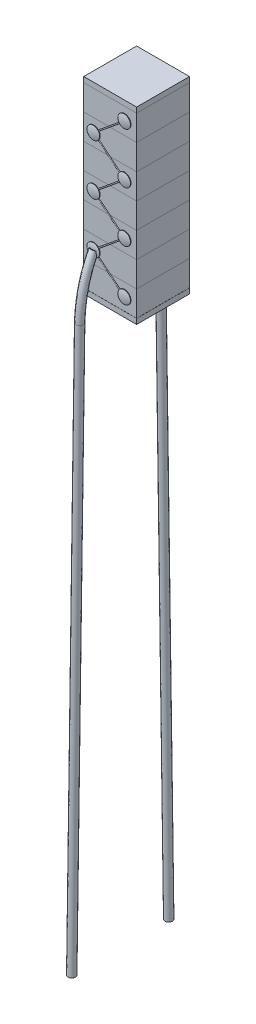
from build123d import *

# Parameters (mm, degrees)
SKETCH1_W                = 5
SKETCH1_H                = 5
BOSS_EXTRUDE1_DEPTH      = 2.4
LPATTERN3_COUNT          = 7
LPATTERN3_PITCH          = 2.4001
SKETCH2_W                = 5
SKETCH2_H                = 5
BOSS_EXTRUDE2_DEPTH      = 0.5
SKETCH7_R                = 0.6
BOSS_EXTRUDE6_DEPTH      = 0.05
DOME1_FACE_RADIUS        = 0.6
DOME1_HEIGHT             = 0.1
DOME5_FACE_RADIUS        = 0.6
DOME5_HEIGHT             = 0.1
DOME6_FACE_RADIUS        = 0.6
DOME6_HEIGHT             = 0.1
DOME7_FACE_RADIUS        = 0.6
DOME7_HEIGHT             = 0.1
SKETCH9_R                = 0.05
SKETCH18_R               = 0.35
DOME10_FACE_RADIUS       = 0.6
DOME10_HEIGHT            = 0.1
DOME11_FACE_RADIUS       = 0.6
DOME11_HEIGHT            = 0.1
DOME12_FACE_RADIUS       = 0.6
DOME12_HEIGHT            = 0.1
MIRROR20_COPY_1_SKETCH_R = 0.05
SKETCH20_W               = 5
SKETCH20_H               = 5
BOSS_EXTRUDE7_DEPTH      = 0.5


with BuildPart() as part:
    # Sketch1 → Boss-Extrude1 (new body)
    with BuildSketch(Plane(origin=(0, 0, 0), x_dir=(1, 0, 0), z_dir=(0, 1, 0))):
        Rectangle(SKETCH1_W, SKETCH1_H)
    extrude(amount=BOSS_EXTRUDE1_DEPTH)


with BuildPart() as lpattern3_1:
    # LPattern3: pattern copy
    add(part.part.moved(Location(Vector(0, 1, 0) * (1 * LPATTERN3_PITCH))))


with BuildPart() as lpattern3_2:
    # LPattern3: pattern copy
    add(part.part.moved(Location(Vector(0, 1, 0) * (2 * LPATTERN3_PITCH))))


with BuildPart() as lpattern3_3:
    # LPattern3: pattern copy
    add(part.part.moved(Location(Vector(0, 1, 0) * (3 * LPATTERN3_PITCH))))

    # Sketch7 → Boss-Extrude6 (add)
    with BuildSketch(Plane.XY.offset(2.5)):
        with Locations((1.368076751, 10.8004)):
            Circle(SKETCH7_R)
        with Locations(Location((-1.547788486, 8.4, 0), (0, 0, 180))):
            Circle(SKETCH7_R)
        with Locations((1.368076751, 6.0002)):
            Circle(SKETCH7_R)
        with Locations((-1.547788486, 3.6001)):
            Circle(SKETCH7_R)
        with Locations((1.368076751, 1.2)):
            Circle(SKETCH7_R)
        with Locations((-1.547788486, 13.2005)):
            Circle(SKETCH7_R)
        with Locations((1.368076751, 15.6006)):
            Circle(SKETCH7_R)
    boss_extrude6 = extrude(amount=BOSS_EXTRUDE6_DEPTH)


with BuildPart() as lpattern3_4:
    # LPattern3: pattern copy
    add(part.part.moved(Location(Vector(0, 1, 0) * (4 * LPATTERN3_PITCH))))


with BuildPart() as lpattern3_5:
    # LPattern3: pattern copy
    add(part.part.moved(Location(Vector(0, 1, 0) * (5 * LPATTERN3_PITCH))))


with BuildPart() as lpattern3_6:
    # LPattern3: pattern copy
    add(part.part.moved(Location(Vector(0, 1, 0) * (6 * LPATTERN3_PITCH))))


with BuildPart() as body_8:
    # Sketch2 → Boss-Extrude2 (new body)
    with BuildSketch(Plane(origin=(0, -0.01, 0), x_dir=(-1, 0, 0), z_dir=(0, -1, 0))):
        Rectangle(SKETCH2_W, SKETCH2_H)
    extrude(amount=BOSS_EXTRUDE2_DEPTH)


with BuildPart() as boss_extrude6_piece_1:
    # of the separate pieces the step leaves, piece 1, a body of its own (boss_extrude6_pieces)
    add(lpattern3_3.part.solids().sort_by_distance((-2.5, 7.2003, -2.5))[0])


with BuildPart() as boss_extrude6_piece_2:
    # of the separate pieces the step leaves, piece 2, a body of its own (boss_extrude6_pieces)
    add(lpattern3_3.part.solids().sort_by_distance((-0.947788486, 3.6001, 2.5))[0])

    # Dome6: a dome of height H over a round flat face of radius A is a cap of a sphere of radius (A * A + H * H) / (2 * H)
    dome6_r = (DOME6_FACE_RADIUS * DOME6_FACE_RADIUS + DOME6_HEIGHT * DOME6_HEIGHT) / (2 * DOME6_HEIGHT)
    dome6_base = Plane((-1.547788486, 3.6001, 2.55), z_dir=(0, 0, 1))
    with Locations(dome6_base.offset(DOME6_HEIGHT - dome6_r)):
        dome6_ball = Sphere(dome6_r, mode=Mode.PRIVATE)
    add(split(dome6_ball, bisect_by=dome6_base, keep=Keep.TOP, mode=Mode.PRIVATE))


with BuildPart() as boss_extrude6_piece_3:
    # of the separate pieces the step leaves, piece 3, a body of its own (boss_extrude6_pieces)
    add(lpattern3_3.part.solids().sort_by_distance((-0.947788486, 13.2005, 2.5))[0])

    # Dome11: a dome of height H over a round flat face of radius A is a cap of a sphere of radius (A * A + H * H) / (2 * H)
    dome11_r = (DOME11_FACE_RADIUS * DOME11_FACE_RADIUS + DOME11_HEIGHT * DOME11_HEIGHT) / (2 * DOME11_HEIGHT)
    dome11_base = Plane((-1.547788486, 13.2005, 2.55), z_dir=(0, 0, 1))
    with Locations(dome11_base.offset(DOME11_HEIGHT - dome11_r)):
        dome11_ball = Sphere(dome11_r, mode=Mode.PRIVATE)
    add(split(dome11_ball, bisect_by=dome11_base, keep=Keep.TOP, mode=Mode.PRIVATE))


with BuildPart() as boss_extrude6_piece_4:
    # of the separate pieces the step leaves, piece 4, a body of its own (boss_extrude6_pieces)
    add(lpattern3_3.part.solids().sort_by_distance((1.968076751, 1.2, 2.5))[0])

    # Dome7: a dome of height H over a round flat face of radius A is a cap of a sphere of radius (A * A + H * H) / (2 * H)
    dome7_r = (DOME7_FACE_RADIUS * DOME7_FACE_RADIUS + DOME7_HEIGHT * DOME7_HEIGHT) / (2 * DOME7_HEIGHT)
    dome7_base = Plane((1.368076751, 1.2, 2.55), z_dir=(0, 0, 1))
    with Locations(dome7_base.offset(DOME7_HEIGHT - dome7_r)):
        dome7_ball = Sphere(dome7_r, mode=Mode.PRIVATE)
    add(split(dome7_ball, bisect_by=dome7_base, keep=Keep.TOP, mode=Mode.PRIVATE))


with BuildPart() as boss_extrude6_piece_5:
    # of the separate pieces the step leaves, piece 5, a body of its own (boss_extrude6_pieces)
    add(lpattern3_3.part.solids().sort_by_distance((1.968076751, 6.0002, 2.5))[0])

    # Dome5: a dome of height H over a round flat face of radius A is a cap of a sphere of radius (A * A + H * H) / (2 * H)
    dome5_r = (DOME5_FACE_RADIUS * DOME5_FACE_RADIUS + DOME5_HEIGHT * DOME5_HEIGHT) / (2 * DOME5_HEIGHT)
    dome5_base = Plane((1.368076751, 6.0002, 2.55), z_dir=(0, 0, 1))
    with Locations(dome5_base.offset(DOME5_HEIGHT - dome5_r)):
        dome5_ball = Sphere(dome5_r, mode=Mode.PRIVATE)
    add(split(dome5_ball, bisect_by=dome5_base, keep=Keep.TOP, mode=Mode.PRIVATE))


with BuildPart() as boss_extrude6_piece_6:
    # of the separate pieces the step leaves, piece 6, a body of its own (boss_extrude6_pieces)
    add(lpattern3_3.part.solids().sort_by_distance((1.968076751, 10.8004, 2.5))[0])

    # Dome12: a dome of height H over a round flat face of radius A is a cap of a sphere of radius (A * A + H * H) / (2 * H)
    dome12_r = (DOME12_FACE_RADIUS * DOME12_FACE_RADIUS + DOME12_HEIGHT * DOME12_HEIGHT) / (2 * DOME12_HEIGHT)
    dome12_base = Plane((1.368076751, 10.8004, 2.55), z_dir=(0, 0, 1))
    with Locations(dome12_base.offset(DOME12_HEIGHT - dome12_r)):
        dome12_ball = Sphere(dome12_r, mode=Mode.PRIVATE)
    add(split(dome12_ball, bisect_by=dome12_base, keep=Keep.TOP, mode=Mode.PRIVATE))


with BuildPart() as boss_extrude6_piece_7:
    # of the separate pieces the step leaves, piece 7, a body of its own (boss_extrude6_pieces)
    add(lpattern3_3.part.solids().sort_by_distance((1.968076751, 15.6006, 2.5))[0])

    # Dome10: a dome of height H over a round flat face of radius A is a cap of a sphere of radius (A * A + H * H) / (2 * H)
    dome10_r = (DOME10_FACE_RADIUS * DOME10_FACE_RADIUS + DOME10_HEIGHT * DOME10_HEIGHT) / (2 * DOME10_HEIGHT)
    dome10_base = Plane((1.368076751, 15.6006, 2.55), z_dir=(0, 0, 1))
    with Locations(dome10_base.offset(DOME10_HEIGHT - dome10_r)):
        dome10_ball = Sphere(dome10_r, mode=Mode.PRIVATE)
    add(split(dome10_ball, bisect_by=dome10_base, keep=Keep.TOP, mode=Mode.PRIVATE))


with BuildPart() as mirror34_copies:
    # Mirror34: Boss-Extrude6 across plane
    add(boss_extrude6.mirror(Plane.XY))


with BuildPart() as lpattern3_4_1:
    add(lpattern3_4.part)

    # the copy of mirror34_joined that lands on this body joins it
    add(mirror34_copies.part.solids().sort_by_distance((1.968076751, 10.8004, -2.5))[0])


with BuildPart() as boss_extrude6_piece_1_1:
    add(boss_extrude6_piece_1.part)

    # the copy of mirror34_joined that lands on this body joins it
    add(mirror34_copies.part.solids().sort_by_distance((-2.147788486, 8.4, -2.5))[0])

    # Dome1: a dome of height H over a round flat face of radius A is a cap of a sphere of radius (A * A + H * H) / (2 * H)
    dome1_r = (DOME1_FACE_RADIUS * DOME1_FACE_RADIUS + DOME1_HEIGHT * DOME1_HEIGHT) / (2 * DOME1_HEIGHT)
    dome1_base = Plane((-1.547788486, 8.4, 2.55), z_dir=(0, 0, 1))
    with Locations(dome1_base.offset(DOME1_HEIGHT - dome1_r)):
        dome1_ball = Sphere(dome1_r, mode=Mode.PRIVATE)
    add(split(dome1_ball, bisect_by=dome1_base, keep=Keep.TOP, mode=Mode.PRIVATE))


with BuildPart() as lpattern3_2_1:
    add(lpattern3_2.part)

    # the copy of mirror34_joined that lands on this body joins it
    add(mirror34_copies.part.solids().sort_by_distance((1.968076751, 6.0002, -2.5))[0])


with BuildPart() as lpattern3_1_1:
    add(lpattern3_1.part)

    # the copy of mirror34_joined that lands on this body joins it
    add(mirror34_copies.part.solids().sort_by_distance((-0.947788486, 3.6001, -2.5))[0])


with BuildPart() as part_1:
    add(part.part)

    # the copy of mirror34_joined that lands on this body joins it
    add(mirror34_copies.part.solids().sort_by_distance((1.968076751, 1.2, -2.5))[0])


    add(lpattern3_1_1.part)  # Sweep1 merges LPattern3_1

    add(lpattern3_2_1.part)  # Sweep1 merges LPattern3_2

    add(boss_extrude6_piece_1_1.part)  # Sweep1 merges Boss-Extrude6 piece 1

    add(boss_extrude6_piece_2.part)  # Sweep1 merges Boss-Extrude6 piece 2

    add(boss_extrude6_piece_4.part)  # Sweep1 merges Boss-Extrude6 piece 4

    add(boss_extrude6_piece_5.part)  # Sweep1 merges Boss-Extrude6 piece 5
    # Sweep1: sweep along a path in Sketch8
    with BuildLine(Plane.XY.offset(2.5)) as sweep1_path:
        Line((-1.547788486, 8.4), (1.368027635, 5.999940428))
        Line((1.368027635, 5.999940428), (-1.547788486, 3.6001))
        Line((-1.547788486, 3.6001), (1.368076751, 1.2))
    # Sketch9 → Sweep1 (sweep)
    with BuildSketch(Plane(origin=(-1.547788486, 8.4, 2.5), x_dir=(0, 0, -1), z_dir=(0.7720862388953024, -0.6355177729288978, 0))):
        Circle(SKETCH9_R)
    sweep1 = sweep(path=sweep1_path.line, transition=Transition.RIGHT)

    # Sweep2: sweep along a path in Sketch17
    with BuildLine() as sweep2_path:  # in the path sketch's own coordinates; laid on its plane below (add() does not lay a ready-made edge on the line's plane)
        Line((4.58491824, -54.772897522), (3.836541994, -1.715359601))
        add(Edge.make_bspline(
            [(3.836541994, -1.715359601), (3.75813778, 0.222344556), (3.367938728, 1.999301306), (2.494410501, 3.611060957)],
            knots=[0, 0, 0, 0, 1, 1, 1, 1], degree=3))
    # Sketch18 → Sweep2 (sweep)
    with BuildSketch(Plane(origin=(-1.55, -54.772897522, 4.58491824), x_dir=(-1, 0, 0), z_dir=(0, -0.9999005394148867, 0.014103590954746349))):
        Circle(SKETCH18_R)
    sweep2 = sweep(path=Plane.ZY.offset(1.55) * sweep2_path.line, transition=Transition.RIGHT)

    # Mirror2: Sweep2 across plane
    add(sweep2.mirror(Plane.XY))

    # Mirror12: Sweep1 across plane
    add(sweep1.mirror(Plane.ZX.offset(8.4)))

    # Mirror20: Sweep1 across plane
    add(sweep1.mirror(Plane.XY))

    # Mirror20 copy 1: sweep along a path in Mirror20 copy 1 path
    with BuildLine(Plane(origin=(0, 16.8, -2.5), x_dir=(1, 0, 0), z_dir=(0, 0, -1))) as mirror20_copy_1_path:
        Line((-1.547788486, 8.4), (1.368027635, 5.999940428))
        Line((1.368027635, 5.999940428), (-1.547788486, 3.6001))
        Line((-1.547788486, 3.6001), (1.368076751, 1.2))
    # Mirror20 copy 1 sketch → Mirror20 copy 1 (sweep)
    with BuildSketch(Plane(origin=(-1.547788486, 8.4, -2.5), x_dir=(0, 0, 1), z_dir=(0.7720862388953024, 0.6355177729288978, 0))):
        Circle(MIRROR20_COPY_1_SKETCH_R)
    sweep(path=mirror20_copy_1_path.line, transition=Transition.RIGHT)


with BuildPart() as lpattern3_5_1:
    add(lpattern3_5.part)

    # the copy of mirror34_joined that lands on this body joins it
    add(mirror34_copies.part.solids().sort_by_distance((-0.947788486, 13.2005, -2.5))[0])


with BuildPart() as lpattern3_6_1:
    add(lpattern3_6.part)

    # the copy of mirror34_joined that lands on this body joins it
    add(mirror34_copies.part.solids().sort_by_distance((1.968076751, 15.6006, -2.5))[0])


with BuildPart() as body_9:
    # Sketch20 → Boss-Extrude7 (new body)
    with BuildSketch(Plane(origin=(0, 16.8007, 0), x_dir=(1, 0, 0), z_dir=(0, 1, 0))):
        Rectangle(SKETCH20_W, SKETCH20_H)
    extrude(amount=BOSS_EXTRUDE7_DEPTH)


solid = Compound([body_8.part, boss_extrude6_piece_3.part, boss_extrude6_piece_6.part, boss_extrude6_piece_7.part, lpattern3_4_1.part, part_1.part, lpattern3_5_1.part, lpattern3_6_1.part, body_9.part])
